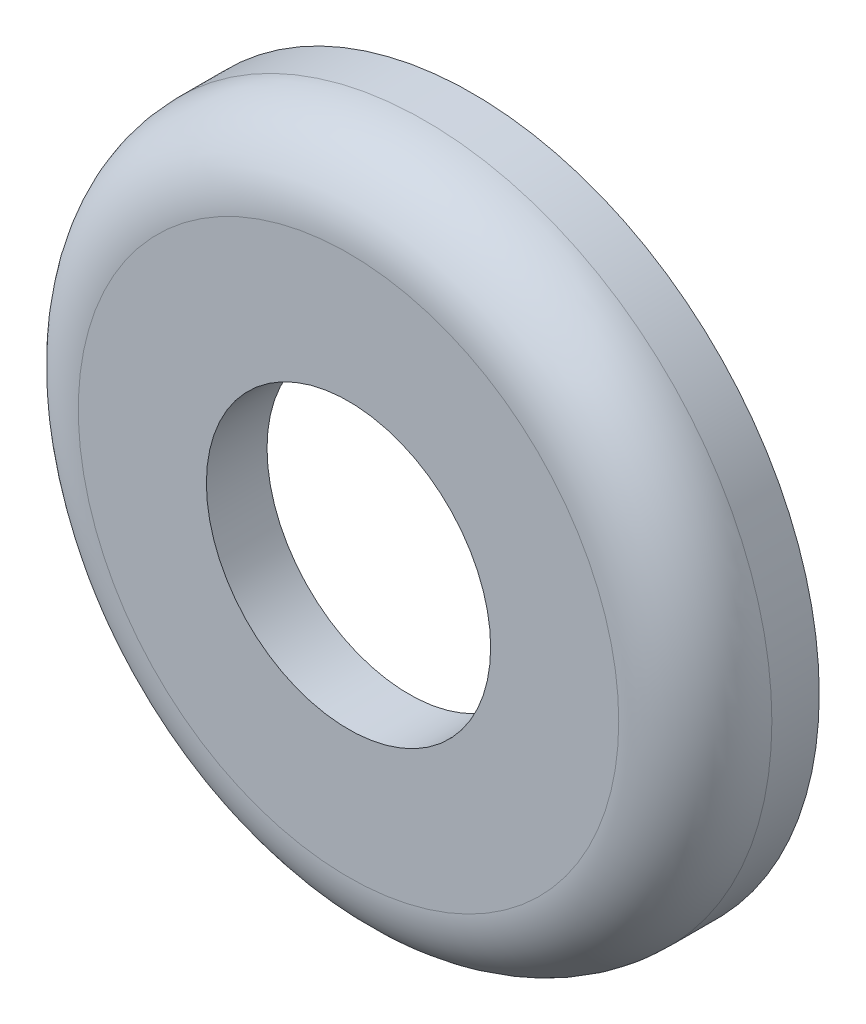
from build123d import *


with BuildPart() as part:
    # Sketch1 → Revolve1 (revolve)
    with BuildSketch(Plane(origin=(0, 0, 0), x_dir=(1, 0, 0), z_dir=(0, 1, 0))):
        with BuildLine():
            ThreePointArc((9.04875, 2.032), (9.281494477, 2.107409957), (9.425791706, 2.304982636))
            Line((9.425791706, 2.304982636), (10.033, 4.1529))
            Line((10.033, 4.1529), (11.6205, 4.1529))
            Line((11.6205, 4.1529), (11.6205, 2.5654))
            ThreePointArc((11.6205, 2.5654), (10.869111736, 0.751388264), (9.0551, 0))
            Line((9.0551, 0), (4.7625, 0))
            Line((4.7625, 0), (4.7625, 2.032))
            Line((4.7625, 2.032), (9.04875, 2.032))
        make_face()
    revolve(axis=Axis((0, 0, 0), (0, 0, -1)))


solid = part.part
